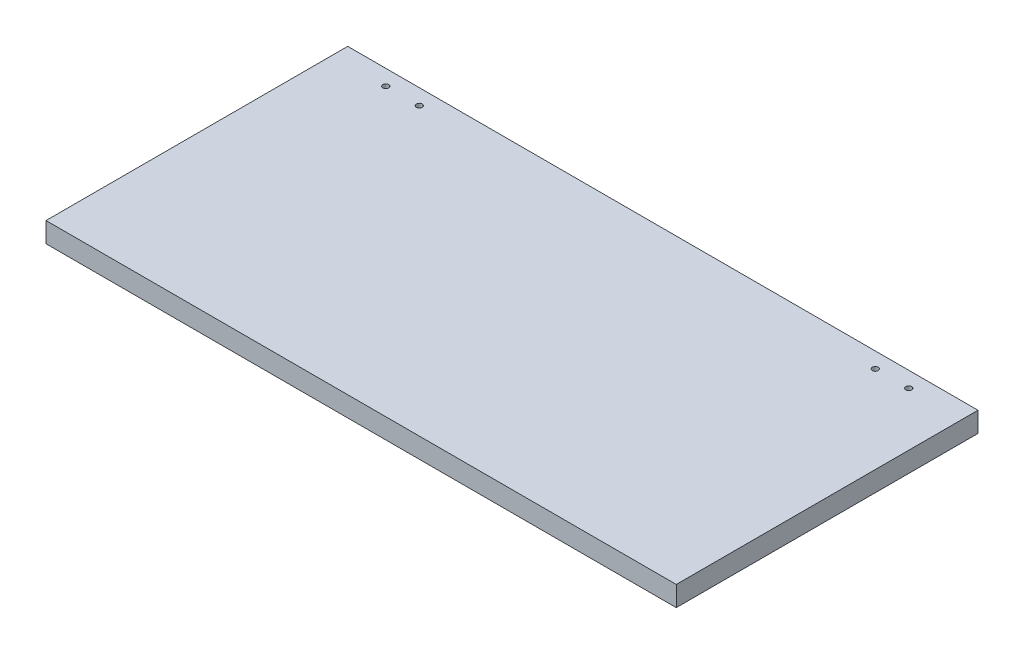
from build123d import *

# Parameters (mm, degrees)
SKETCH2_W           = 470
SKETCH2_H           = 225
BOSS_EXTRUDE1_DEPTH = 15
SKETCH3_R           = 2.2
CUT_EXTRUDE1_DEPTH  = 16


with BuildPart() as part:
    # Sketch2 → Boss-Extrude1 (new body)
    with BuildSketch(Plane(origin=(0, 0, 0), x_dir=(1, 0, 0), z_dir=(0, 1, 0))):
        Rectangle(SKETCH2_W, SKETCH2_H)
    extrude(amount=BOSS_EXTRUDE1_DEPTH)

    # Sketch3 → Cut-Extrude1 (cut, through all)
    with BuildSketch(Plane(origin=(0, 15, 0), x_dir=(1, 0, 0), z_dir=(0, 1, 0))):
        with Locations((-195, 100.9)):
            Circle(SKETCH3_R)
        with Locations((-170, 100.9)):
            Circle(SKETCH3_R)
        with Locations((195, 100.9)):
            Circle(SKETCH3_R)
        with Locations((170.000001969, 100.909922977)):
            Circle(SKETCH3_R)
    extrude(amount=-CUT_EXTRUDE1_DEPTH, mode=Mode.SUBTRACT)


solid = part.part
